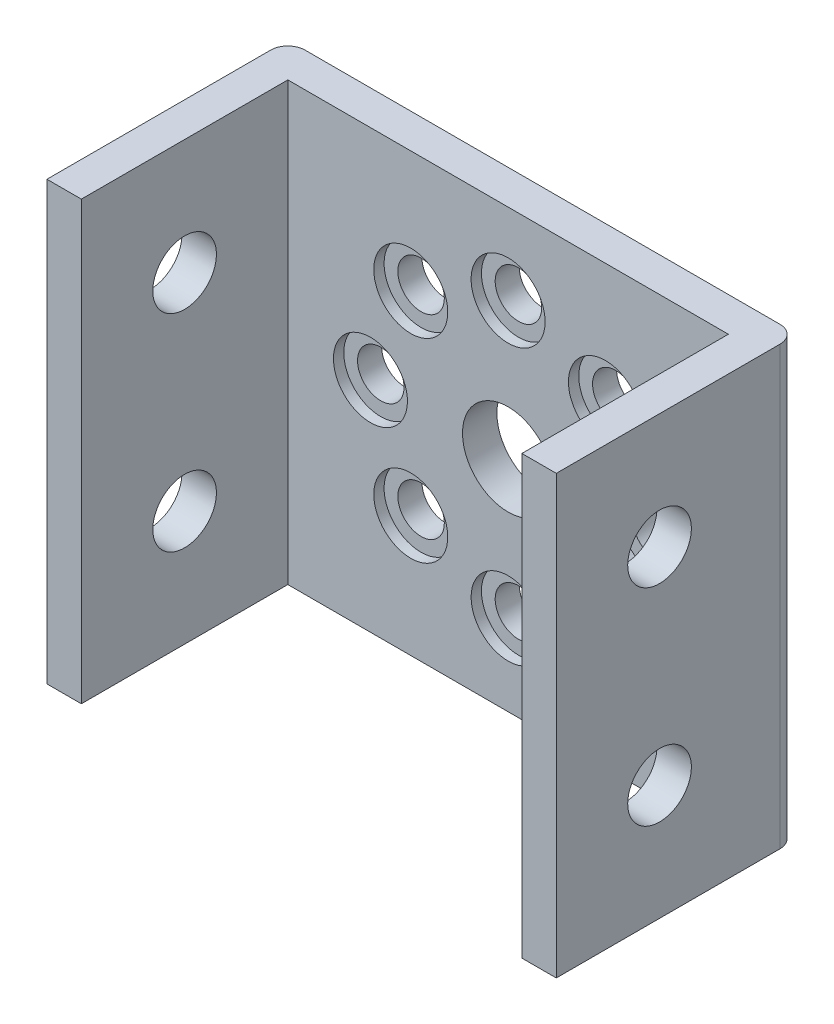
from build123d import *

# Parameters (mm, degrees)
BOSS_EXTRUDE1_DEPTH = 12.7
SKETCH2_R           = 1.85
CUT_EXTRUDE1_DEPTH  = 30.6
SKETCH3_R           = 2.65
CUT_EXTRUDE2_DEPTH  = 15
SKETCH4_R           = 1.35
CUT_EXTRUDE3_DEPTH  = 3
SKETCH5_R           = 2.15
CUT_EXTRUDE4_DEPTH  = 0.6
CIRPATTERN1_COUNT   = 8
FILLET1_R           = 1


with BuildPart() as part:
    # Sketch1 → Boss-Extrude1 (new body, symmetric)
    with BuildSketch(Plane(origin=(0, 0, 0), x_dir=(1, 0, 0), z_dir=(0, 1, 0))):
        Polygon((-14.8, 0), (14.8, 0), (14.8, -14), (12.8, -14), (12.8, -2), (-12.8, -2), (-12.8, -14), (-14.8, -14), align=None)
    extrude(amount=BOSS_EXTRUDE1_DEPTH, both=True)

    # Sketch2 → Cut-Extrude1 (cut, through all)
    with BuildSketch(Plane.ZY.offset(14.8)):
        with Locations((8, -6)):
            Circle(SKETCH2_R)
        with Locations((8, 6)):
            Circle(SKETCH2_R)
    extrude(amount=-CUT_EXTRUDE1_DEPTH, mode=Mode.SUBTRACT)

    # Sketch3 → Cut-Extrude2 (cut, through all)
    with BuildSketch(Plane(origin=(0, 0, 0), x_dir=(-1, 0, 0), z_dir=(0, 0, -1))):
        Circle(SKETCH3_R)
    extrude(amount=-CUT_EXTRUDE2_DEPTH, mode=Mode.SUBTRACT)

    # Sketch4 → Cut-Extrude3 (cut, through all)
    with BuildSketch(Plane.XY.offset(2)):
        with Locations((0, 8)):
            Circle(SKETCH4_R)
    cut_extrude3 = extrude(amount=-CUT_EXTRUDE3_DEPTH, mode=Mode.SUBTRACT)

    # Sketch5 → Cut-Extrude4 (cut)
    with BuildSketch(Plane.XY.offset(2)):
        with Locations((0, 8)):
            Circle(SKETCH5_R)
    cut_extrude4 = extrude(amount=-CUT_EXTRUDE4_DEPTH, mode=Mode.SUBTRACT)

    # CirPattern1: Cut-Extrude3, Cut-Extrude4 ×8 about axis
    cirpattern1_axis = Axis((0, 0, 0), (0, 0, 1))
    for i in range(1, CIRPATTERN1_COUNT):
        add(cut_extrude3.rotate(cirpattern1_axis, i * 360 / CIRPATTERN1_COUNT), mode=Mode.SUBTRACT)
        add(cut_extrude4.rotate(cirpattern1_axis, i * 360 / CIRPATTERN1_COUNT), mode=Mode.SUBTRACT)

    # Fillet1
    fillet1_edges = [part.edges().sort_by_distance(p)[0] for p in [
        (-14.8, 0, 0),
        (14.8, 0, 0),
    ]]
    fillet(fillet1_edges, radius=FILLET1_R)


solid = part.part
